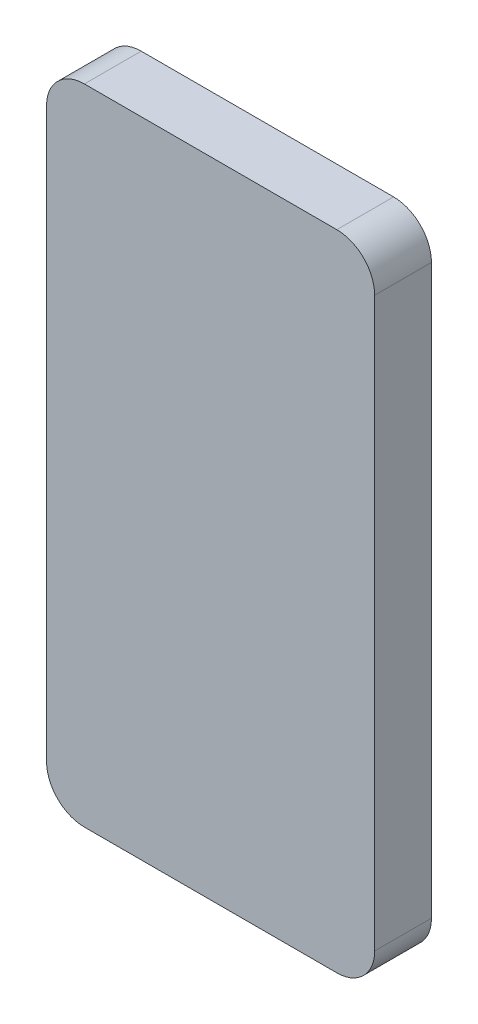
from build123d import *

# Parameters (mm, degrees)
SKETCH1_W           = 66.04
SKETCH1_H           = 129.54
BOSS_EXTRUDE1_DEPTH = 11.43
FILLET1_R           = 7.62


with BuildPart() as part:
    # Sketch1 → Boss-Extrude1 (new body)
    with BuildSketch(Plane.XY):
        Rectangle(SKETCH1_W, SKETCH1_H)
    extrude(amount=BOSS_EXTRUDE1_DEPTH)

    # Fillet1
    fillet1_edges = [part.edges().sort_by_distance(p)[0] for p in [
        (33.02, -64.77, 5.715),
        (-33.02, -64.77, 5.715),
        (-33.02, 64.77, 5.715),
        (33.02, 64.77, 5.715),
    ]]
    fillet(fillet1_edges, radius=FILLET1_R)


solid = part.part
